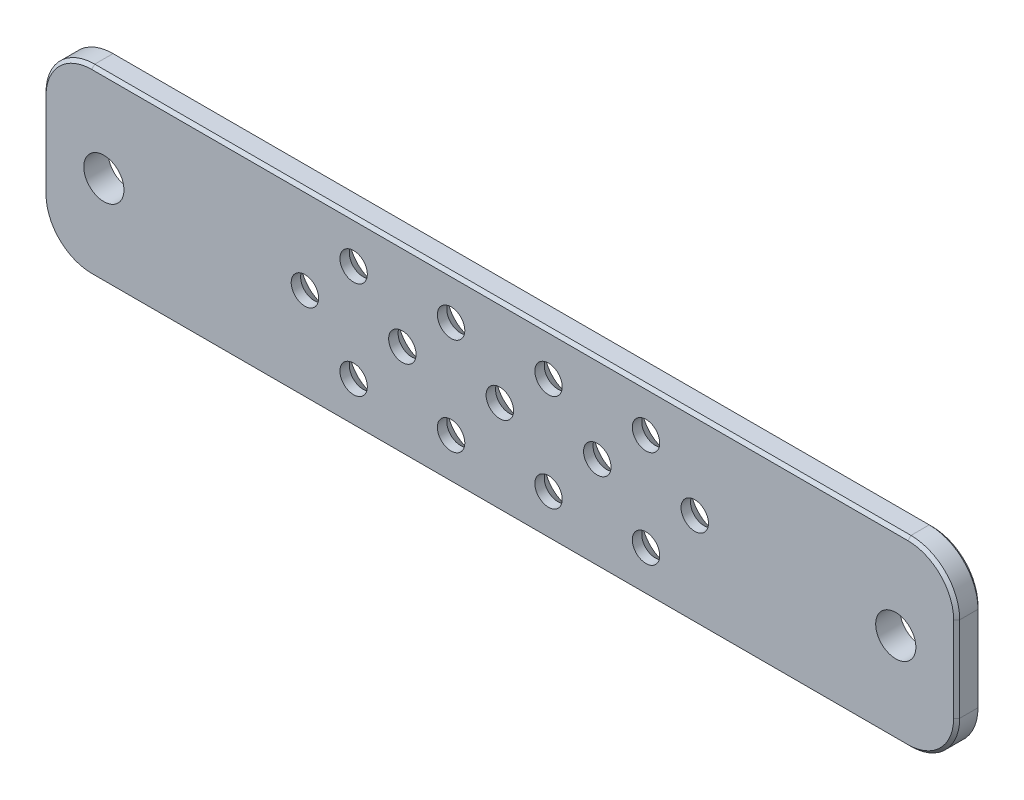
from build123d import *

# Parameters (mm, degrees)
ESQUISSE1_W                                 = 150
ESQUISSE1_H                                 = 30
BOSS_EXTRU_1_DEPTH                          = 4
FRAISAGE_POUR_VIS_T_TE_FRAIS_E_M41_AT_COUNT = 2
FRAISAGE_POUR_VIS_T_TE_FRAIS_E_M41_AT_PITCH = 16
FRAISAGE_POUR_VIS_T_TE_FRAIS_E_M41_2_COUNT  = 2
FRAISAGE_POUR_VIS_T_TE_FRAIS_E_M41_2_PITCH  = 10.908274416
FRAISAGE_POUR_VIS_T_TE_FRAIS_E_M41_3_COUNT  = 2
FRAISAGE_POUR_VIS_T_TE_FRAIS_E_M41_3_PITCH  = 10.908274416
FRAISAGE_POUR_VIS_T_TE_FRAIS_E_M41_4_COUNT  = 2
FRAISAGE_POUR_VIS_T_TE_FRAIS_E_M41_4_PITCH  = 16
FRAISAGE_POUR_VIS_T_TE_FRAIS_E_M41_5_COUNT  = 2
FRAISAGE_POUR_VIS_T_TE_FRAIS_E_M41_5_PITCH  = 22.627416998
FRAISAGE_POUR_VIS_T_TE_FRAIS_E_M41_6_COUNT  = 2
FRAISAGE_POUR_VIS_T_TE_FRAIS_E_M41_6_PITCH  = 25.119523298
FRAISAGE_POUR_VIS_T_TE_FRAIS_E_M41_7_COUNT  = 2
FRAISAGE_POUR_VIS_T_TE_FRAIS_E_M41_7_PITCH  = 16
FRAISAGE_POUR_VIS_T_TE_FRAIS_E_M41_8_COUNT  = 2
FRAISAGE_POUR_VIS_T_TE_FRAIS_E_M41_8_PITCH  = 25.119523298
FRAISAGE_POUR_VIS_T_TE_FRAIS_E_M41_9_COUNT  = 2
FRAISAGE_POUR_VIS_T_TE_FRAIS_E_M41_9_PITCH  = 22.627416998
FRAISAGE_POUR_VIS_T_TE_FRAIS_E_M41_10_COUNT = 2
FRAISAGE_POUR_VIS_T_TE_FRAIS_E_M41_10_PITCH = 32
FRAISAGE_POUR_VIS_T_TE_FRAIS_E_M41_11_COUNT = 2
FRAISAGE_POUR_VIS_T_TE_FRAIS_E_M41_11_PITCH = 40.681573848
FRAISAGE_POUR_VIS_T_TE_FRAIS_E_M41_12_COUNT = 2
FRAISAGE_POUR_VIS_T_TE_FRAIS_E_M41_12_PITCH = 35.77708764
D_GAGEMENT_M61_D                            = 6.6
CONG_1_R                                    = 8
CHANFREIN1_SIZE                             = 0.5


with BuildPart() as part:
    # Esquisse1 → Boss.-Extru.1 (new body)
    with BuildSketch(Plane.XY):
        Rectangle(ESQUISSE1_W, ESQUISSE1_H)
    extrude(amount=BOSS_EXTRU_1_DEPTH)

    # Esquisse3 → Fraisage pour vis à tête fraisée M41 (revolve, cut)
    with BuildSketch(Plane(origin=(8, 8, 0), x_dir=(0, 1, 0), z_dir=(1, 0, 0))):
        Polygon((0, 0), (0, 4), (2.25, 4), (2.25, 2.45), (4.7, 0), align=None)
    fraisage_pour_vis_t_te_frais_e_m41 = revolve(axis=Axis((8, 8, -6.35), (0, 0, 1)), mode=Mode.SUBTRACT)

    # Fraisage pour vis à tête fraisée M41 at: Fraisage pour vis à tête fraisée M41 ×2
    with Locations(*[(0, -i * FRAISAGE_POUR_VIS_T_TE_FRAIS_E_M41_AT_PITCH, 0) for i in range(1, FRAISAGE_POUR_VIS_T_TE_FRAIS_E_M41_AT_COUNT)]):
        add(fraisage_pour_vis_t_te_frais_e_m41, mode=Mode.SUBTRACT)

    # Fraisage pour vis _ t_te frais_e M41 2: Fraisage pour vis à tête fraisée M41 ×2
    with Locations(*[Vector(0.733388224, -0.679810057, 0) * (i * FRAISAGE_POUR_VIS_T_TE_FRAIS_E_M41_2_PITCH) for i in range(1, FRAISAGE_POUR_VIS_T_TE_FRAIS_E_M41_2_COUNT)]):
        add(fraisage_pour_vis_t_te_frais_e_m41, mode=Mode.SUBTRACT)

    # Fraisage pour vis _ t_te frais_e M41 3: Fraisage pour vis à tête fraisée M41 ×2
    with Locations(*[Vector(-0.733388224, -0.679810057, 0) * (i * FRAISAGE_POUR_VIS_T_TE_FRAIS_E_M41_3_PITCH) for i in range(1, FRAISAGE_POUR_VIS_T_TE_FRAIS_E_M41_3_COUNT)]):
        add(fraisage_pour_vis_t_te_frais_e_m41, mode=Mode.SUBTRACT)

    # Fraisage pour vis _ t_te frais_e M41 4: Fraisage pour vis à tête fraisée M41 ×2
    with Locations(*[(-i * FRAISAGE_POUR_VIS_T_TE_FRAIS_E_M41_4_PITCH, 0, 0) for i in range(1, FRAISAGE_POUR_VIS_T_TE_FRAIS_E_M41_4_COUNT)]):
        add(fraisage_pour_vis_t_te_frais_e_m41, mode=Mode.SUBTRACT)

    # Fraisage pour vis _ t_te frais_e M41 5: Fraisage pour vis à tête fraisée M41 ×2
    with Locations(*[Vector(-0.707106781, -0.707106781, 0) * (i * FRAISAGE_POUR_VIS_T_TE_FRAIS_E_M41_5_PITCH) for i in range(1, FRAISAGE_POUR_VIS_T_TE_FRAIS_E_M41_5_COUNT)]):
        add(fraisage_pour_vis_t_te_frais_e_m41, mode=Mode.SUBTRACT)

    # Fraisage pour vis _ t_te frais_e M41 6: Fraisage pour vis à tête fraisée M41 ×2
    with Locations(*[Vector(-0.955432144, -0.295210803, 0) * (i * FRAISAGE_POUR_VIS_T_TE_FRAIS_E_M41_6_PITCH) for i in range(1, FRAISAGE_POUR_VIS_T_TE_FRAIS_E_M41_6_COUNT)]):
        add(fraisage_pour_vis_t_te_frais_e_m41, mode=Mode.SUBTRACT)

    # Fraisage pour vis _ t_te frais_e M41 7: Fraisage pour vis à tête fraisée M41 ×2
    with Locations(*[(i * FRAISAGE_POUR_VIS_T_TE_FRAIS_E_M41_7_PITCH, 0, 0) for i in range(1, FRAISAGE_POUR_VIS_T_TE_FRAIS_E_M41_7_COUNT)]):
        add(fraisage_pour_vis_t_te_frais_e_m41, mode=Mode.SUBTRACT)

    # Fraisage pour vis _ t_te frais_e M41 8: Fraisage pour vis à tête fraisée M41 ×2
    with Locations(*[Vector(0.955432144, -0.295210803, 0) * (i * FRAISAGE_POUR_VIS_T_TE_FRAIS_E_M41_8_PITCH) for i in range(1, FRAISAGE_POUR_VIS_T_TE_FRAIS_E_M41_8_COUNT)]):
        add(fraisage_pour_vis_t_te_frais_e_m41, mode=Mode.SUBTRACT)

    # Fraisage pour vis _ t_te frais_e M41 9: Fraisage pour vis à tête fraisée M41 ×2
    with Locations(*[Vector(0.707106781, -0.707106781, 0) * (i * FRAISAGE_POUR_VIS_T_TE_FRAIS_E_M41_9_PITCH) for i in range(1, FRAISAGE_POUR_VIS_T_TE_FRAIS_E_M41_9_COUNT)]):
        add(fraisage_pour_vis_t_te_frais_e_m41, mode=Mode.SUBTRACT)

    # Fraisage pour vis _ t_te frais_e M41 10: Fraisage pour vis à tête fraisée M41 ×2
    with Locations(*[(-i * FRAISAGE_POUR_VIS_T_TE_FRAIS_E_M41_10_PITCH, 0, 0) for i in range(1, FRAISAGE_POUR_VIS_T_TE_FRAIS_E_M41_10_COUNT)]):
        add(fraisage_pour_vis_t_te_frais_e_m41, mode=Mode.SUBTRACT)

    # Fraisage pour vis _ t_te frais_e M41 11: Fraisage pour vis à tête fraisée M41 ×2
    with Locations(*[Vector(-0.983246129, -0.182282885, 0) * (i * FRAISAGE_POUR_VIS_T_TE_FRAIS_E_M41_11_PITCH) for i in range(1, FRAISAGE_POUR_VIS_T_TE_FRAIS_E_M41_11_COUNT)]):
        add(fraisage_pour_vis_t_te_frais_e_m41, mode=Mode.SUBTRACT)

    # Fraisage pour vis _ t_te frais_e M41 12: Fraisage pour vis à tête fraisée M41 ×2
    with Locations(*[Vector(-0.894427191, -0.447213595, 0) * (i * FRAISAGE_POUR_VIS_T_TE_FRAIS_E_M41_12_PITCH) for i in range(1, FRAISAGE_POUR_VIS_T_TE_FRAIS_E_M41_12_COUNT)]):
        add(fraisage_pour_vis_t_te_frais_e_m41, mode=Mode.SUBTRACT)

    # Dégagement M61 (through all)
    with Locations(Plane(origin=(0, 0, 0), x_dir=(-1, 0, 0), z_dir=(0, 0, -1))):
        with Locations((-65, 0), (65, 0)):
            Hole(D_GAGEMENT_M61_D / 2)

    # Congé1
    cong_1_edges = [part.edges().sort_by_distance(p)[0] for p in [
        (-75, 15, 2),
        (75, 15, 2),
        (75, -15, 2),
        (-75, -15, 2),
    ]]
    fillet(cong_1_edges, radius=CONG_1_R)

    # Chanfrein1
    chanfrein1_edges = [part.edges().sort_by_distance(p)[0] for p in [
        (0, 15, 0),
        (0, 15, 4),
        (-75, 0, 0),
        (75, 0, 0),
        (0, -15, 0),
        (-72.656854249, 12.656854249, 0),
        (-72.656854249, -12.656854249, 0),
        (72.656854249, -12.656854249, 0),
        (72.656854249, 12.656854249, 0),
        (75, 0, 4),
        (-75, 0, 4),
        (0, -15, 4),
        (-72.656854249, 12.656854249, 4),
        (-72.656854249, -12.656854249, 4),
        (72.656854249, -12.656854249, 4),
        (72.656854249, 12.656854249, 4),
    ]]
    chamfer(chanfrein1_edges, length=CHANFREIN1_SIZE)


solid = part.part
